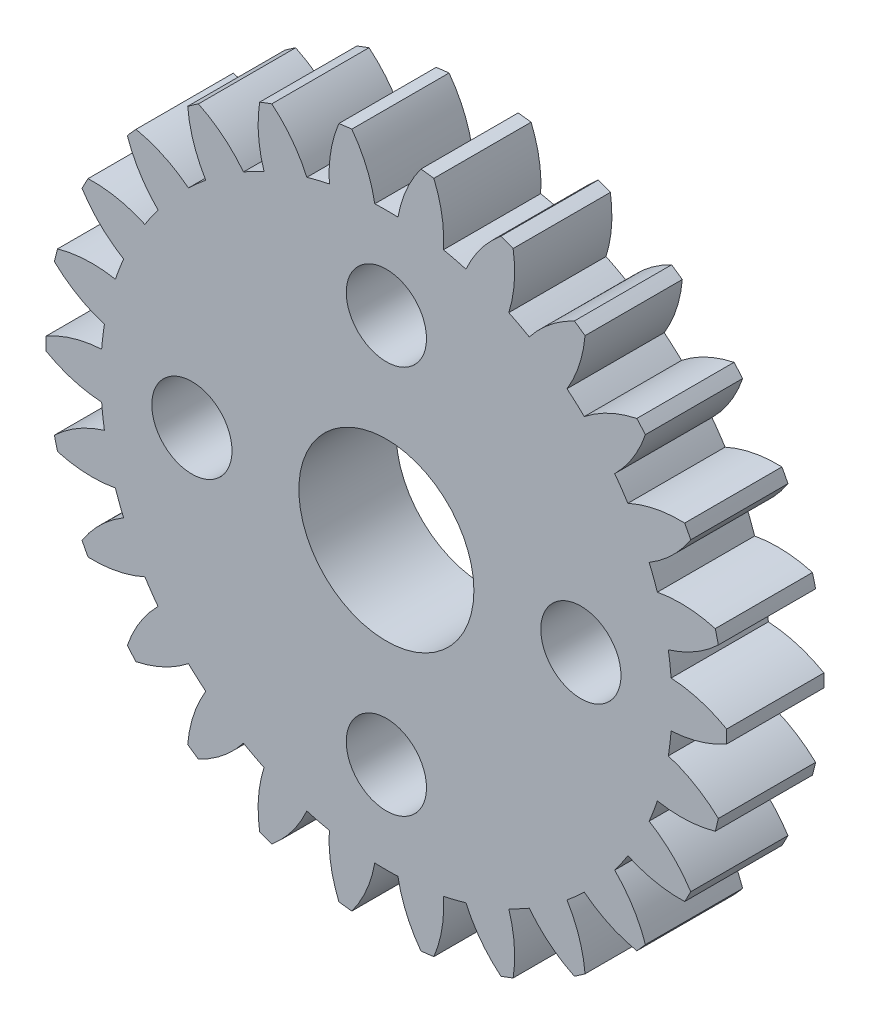
from build123d import *

# Parameters (mm, degrees)
SKETCH_1_R               = 14
EXTRUDE_1_DEPTH          = 4
CUT_EXTRUDE_1_DEPTH      = 4
PATTERN_CIRCULAR_1_COUNT = 26
CUT_EXTRUDE_2_REACH      = 6
SKETCH_5_R               = 3.6
SKETCH_5_R_2             = 1.65


with BuildPart() as part:
    # 草圖1 → 填料-伸長1 (new body)
    with BuildSketch(Plane.XY):
        Circle(SKETCH_1_R)
    extrude(amount=EXTRUDE_1_DEPTH)

    # 草圖4 → 除料-伸長1 (cut)
    with BuildSketch(Plane.XY.offset(4)):
        with BuildLine():
            ThreePointArc((-1.421594657, 13.927636865), (0, 14), (1.421594657, 13.927636865))
            ThreePointArc((1.421594657, 13.927636865), (0.822322703, 12.888806427), (0.476978653, 11.74031479))
            ThreePointArc((0.476978653, 11.74031479), (0, 11.75), (-0.476978653, 11.74031479))
            ThreePointArc((-0.476978653, 11.74031479), (-0.822322703, 12.888806427), (-1.421594657, 13.927636865))
        make_face()
    cut_extrude_1 = extrude(amount=-CUT_EXTRUDE_1_DEPTH, mode=Mode.SUBTRACT)

    # 環狀複製排列1: 除料-伸長1 ×26 about axis
    pattern_circular_1_axis = Axis((0, 0, 0), (0, 0, 1))
    for i in range(1, PATTERN_CIRCULAR_1_COUNT):
        add(cut_extrude_1.rotate(pattern_circular_1_axis, i * 360 / PATTERN_CIRCULAR_1_COUNT), mode=Mode.SUBTRACT)

    # 草圖5 → 除料-伸長2 (cut, up to next)
    with BuildSketch(Plane.XY.offset(4), mode=Mode.PRIVATE) as cut_extrude_2_sk1:
        Circle(SKETCH_5_R)
    cut_extrude_2_tool1 = extrude(cut_extrude_2_sk1.sketch, amount=-CUT_EXTRUDE_2_REACH, mode=Mode.PRIVATE) & part.part
    add(cut_extrude_2_tool1.solids().sort_by_distance((0, 0, 4))[0], mode=Mode.SUBTRACT)
    # 草圖5 → 除料-伸長2 (cut, up to next)
    with BuildSketch(Plane.XY.offset(4), mode=Mode.PRIVATE) as cut_extrude_2_sk2:
        with Locations((0, 8)):
            Circle(SKETCH_5_R_2)
    cut_extrude_2_tool2 = extrude(cut_extrude_2_sk2.sketch, amount=-CUT_EXTRUDE_2_REACH, mode=Mode.PRIVATE) & part.part
    add(cut_extrude_2_tool2.solids().sort_by_distance((0, 8, 4))[0], mode=Mode.SUBTRACT)
    # 草圖5 → 除料-伸長2 (cut, up to next)
    with BuildSketch(Plane.XY.offset(4), mode=Mode.PRIVATE) as cut_extrude_2_sk3:
        with Locations((8, 0)):
            Circle(SKETCH_5_R_2)
    cut_extrude_2_tool3 = extrude(cut_extrude_2_sk3.sketch, amount=-CUT_EXTRUDE_2_REACH, mode=Mode.PRIVATE) & part.part
    add(cut_extrude_2_tool3.solids().sort_by_distance((8, 0, 4))[0], mode=Mode.SUBTRACT)
    # 草圖5 → 除料-伸長2 (cut, up to next)
    with BuildSketch(Plane.XY.offset(4), mode=Mode.PRIVATE) as cut_extrude_2_sk4:
        with Locations((0, -8)):
            Circle(SKETCH_5_R_2)
    cut_extrude_2_tool4 = extrude(cut_extrude_2_sk4.sketch, amount=-CUT_EXTRUDE_2_REACH, mode=Mode.PRIVATE) & part.part
    add(cut_extrude_2_tool4.solids().sort_by_distance((0, -8, 4))[0], mode=Mode.SUBTRACT)
    # 草圖5 → 除料-伸長2 (cut, up to next)
    with BuildSketch(Plane.XY.offset(4), mode=Mode.PRIVATE) as cut_extrude_2_sk5:
        with Locations((-8, 0)):
            Circle(SKETCH_5_R_2)
    cut_extrude_2_tool5 = extrude(cut_extrude_2_sk5.sketch, amount=-CUT_EXTRUDE_2_REACH, mode=Mode.PRIVATE) & part.part
    add(cut_extrude_2_tool5.solids().sort_by_distance((-8, 0, 4))[0], mode=Mode.SUBTRACT)


solid = part.part
